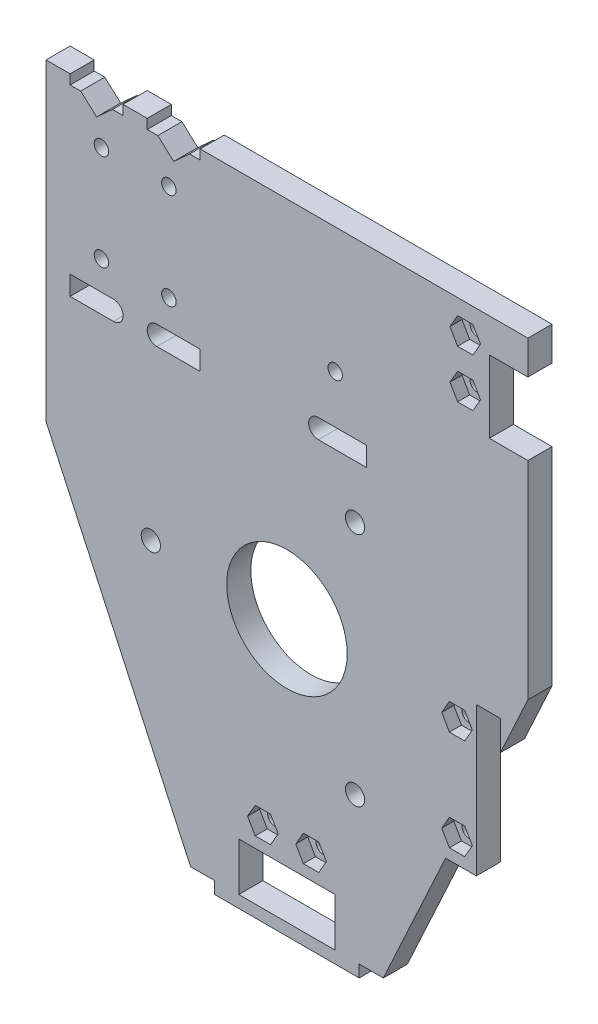
from build123d import *

# Parameters (mm, degrees)
SKETCH_1_W          = 100
SKETCH_1_H          = 130
EXTRUDE_1_DEPTH     = 8
SKETCH_3_W          = 20
SKETCH_3_H          = 10
CUT_EXTRUDE_1_DEPTH = 8
SKETCH_4_R          = 1.5
SKETCH_4_W          = 8
SKETCH_4_H          = 15
CUT_EXTRUDE_2_DEPTH = 9
CUT_EXTRUDE_6_DEPTH = 2.5
SKETCH_10_R         = 12.5
SKETCH_10_W         = 5
SKETCH_10_H         = 30.8
CUT_EXTRUDE_7_DEPTH = 9
EXTRUDE_3_DEPTH     = 8
SKETCH_5_R          = 2
SKETCH_5_R_2        = 1.5
CUT_EXTRUDE_3_DEPTH = 9
SKETCH_11_W         = 30
SKETCH_11_H         = 2.5
EXTRUDE_2_DEPTH     = 8
CUT_EXTRUDE_8_DEPTH = 2.5
SKETCH_15_W         = 100
SKETCH_15_H         = 135
CUT_EXTRUDE_9_DEPTH = 3


with BuildPart() as part:
    # 草图1 → 凸台-拉伸1 (new body)
    with BuildSketch(Plane.XY):
        with Locations((50, 65)):
            Rectangle(SKETCH_1_W, SKETCH_1_H)
    extrude(amount=EXTRUDE_1_DEPTH)

    # 草图3 → 切除-拉伸1 (cut)
    with BuildSketch(Plane.XY.offset(8)):
        with Locations((50, 5)):
            Rectangle(SKETCH_3_W, SKETCH_3_H)
        Polygon((0, 0), (30, 0), (0, 65), align=None)
        Polygon((100, 0), (100, 65), (70, 0), align=None)
    extrude(amount=-CUT_EXTRUDE_1_DEPTH, mode=Mode.SUBTRACT)

    # 草图4 → 切除-拉伸2 (cut, through all)
    with BuildSketch(Plane(origin=(0, 0, 0), x_dir=(-1, 0, 0), z_dir=(0, 0, -1))):
        with Locations((-87, 124)):
            Circle(SKETCH_4_R)
        with Locations((-25.5, 100)):
            Circle(SKETCH_4_R)
        with Locations((-11.5, 100)):
            Circle(SKETCH_4_R)
        with Locations((-11.5, 120)):
            Circle(SKETCH_4_R)
        with Locations((-25.5, 120)):
            Circle(SKETCH_4_R)
        with Locations((-60, 104)):
            Circle(SKETCH_4_R)
        with Locations((-45, 15)):
            Circle(SKETCH_4_R)
        with Locations((-55, 15)):
            Circle(SKETCH_4_R)
        with Locations((-87, 114)):
            Circle(SKETCH_4_R)
        with BuildLine():
            Line((-56.5, 94), (-66.5, 94))
            Line((-66.5, 94), (-66.5, 90))
            Line((-66.5, 90), (-56.5, 90))
            ThreePointArc((-56.5, 90), (-54.5, 92), (-56.5, 94))
        make_face()
        with Locations((-96, 115.5)):
            Rectangle(SKETCH_4_W, SKETCH_4_H)
        with BuildLine():
            Line((-32, 94), (-32, 90))
            Line((-32, 90), (-23, 90))
            ThreePointArc((-23, 90), (-21, 92), (-23, 94))
            Line((-23, 94), (-32, 94))
        make_face()
        with BuildLine():
            Line((-5, 94), (-5, 90))
            Line((-5, 90), (-14, 90))
            ThreePointArc((-14, 90), (-16, 92), (-14, 94))
            Line((-14, 94), (-5, 94))
        make_face()
        Polygon((-10.5, 125), (-13.8, 128), (-16, 128), (-16, 130), (-5, 130), (-5, 128), (-7.2, 128), align=None)
        Polygon((-26.5, 125), (-29.8, 128), (-32, 128), (-32, 130), (-21, 130), (-21, 128), (-23.2, 128), align=None)
    extrude(amount=-CUT_EXTRUDE_2_DEPTH, mode=Mode.SUBTRACT)

    # 草图9 → 切除-拉伸6 (cut)
    with BuildSketch(Plane.XY.offset(8)):
        Polygon((90.175426481, 124), (88.58771324, 126.75), (85.41228676, 126.75), (83.824573519, 124), (85.41228676, 121.25), (88.58771324, 121.25), align=None)
        Polygon((90.175426481, 114), (88.58771324, 116.75), (85.41228676, 116.75), (83.824573519, 114), (85.41228676, 111.25), (88.58771324, 111.25), align=None)
        Polygon((48.175426481, 15), (46.58771324, 17.75), (43.41228676, 17.75), (41.824573519, 15), (43.41228676, 12.25), (46.58771324, 12.25), align=None)
        Polygon((58.175426481, 15), (56.58771324, 17.75), (53.41228676, 17.75), (51.824573519, 15), (53.41228676, 12.25), (56.58771324, 12.25), align=None)
    extrude(amount=-CUT_EXTRUDE_6_DEPTH, mode=Mode.SUBTRACT)

    # 草图10 → 切除-拉伸7 (cut, through all)
    with BuildSketch(Plane.XY.offset(8)):
        with Locations((50, 54.5)):
            Circle(SKETCH_10_R)
        with Locations((91.8, 43.4)):
            Rectangle(SKETCH_10_W, SKETCH_10_H)
    extrude(amount=-CUT_EXTRUDE_7_DEPTH, mode=Mode.SUBTRACT)

    # 草图12 → 凸台-拉伸3 (add)
    with BuildSketch(Plane.XY.offset(8)):
        Polygon((89.3, 41.816666667), (82.923076923, 28), (89.3, 28), align=None)
    extrude(amount=-EXTRUDE_3_DEPTH)

    # 草图5 → 切除-拉伸3 (cut, through all)
    with BuildSketch(Plane.XY.offset(8)):
        with Locations((21.75, 54.5)):
            Circle(SKETCH_5_R)
        with Locations((64.125, 78.965217657)):
            Circle(SKETCH_5_R)
        with Locations((64.125, 30.034782343)):
            Circle(SKETCH_5_R)
        with Locations((85.3, 53.8)):
            Circle(SKETCH_5_R_2)
        with Locations((85.3, 33)):
            Circle(SKETCH_5_R_2)
    extrude(amount=-CUT_EXTRUDE_3_DEPTH, mode=Mode.SUBTRACT)

    # 草图11 → 凸台-拉伸2 (add)
    with BuildSketch(Plane.XY.offset(8)):
        with Locations((50, -1.25)):
            Rectangle(SKETCH_11_W, SKETCH_11_H)
    extrude(amount=-EXTRUDE_2_DEPTH)

    # 草图14 → 切除-拉伸8 (cut)
    with BuildSketch(Plane.XY.offset(8)):
        Polygon((88.475426481, 53.8), (86.88771324, 56.55), (83.71228676, 56.55), (82.124573519, 53.8), (83.71228676, 51.05), (86.88771324, 51.05), align=None)
        Polygon((88.475426481, 33), (86.88771324, 35.75), (83.71228676, 35.75), (82.124573519, 33), (83.71228676, 30.25), (86.88771324, 30.25), align=None)
    extrude(amount=-CUT_EXTRUDE_8_DEPTH, mode=Mode.SUBTRACT)

    # 草图15 → 切除-拉伸9 (cut)
    with BuildSketch(Plane(origin=(0, 0, 0), x_dir=(-1, 0, 0), z_dir=(0, 0, -1))):
        with Locations((-50, 62.5)):
            Rectangle(SKETCH_15_W, SKETCH_15_H)
    extrude(amount=-CUT_EXTRUDE_9_DEPTH, mode=Mode.SUBTRACT)


solid = part.part
